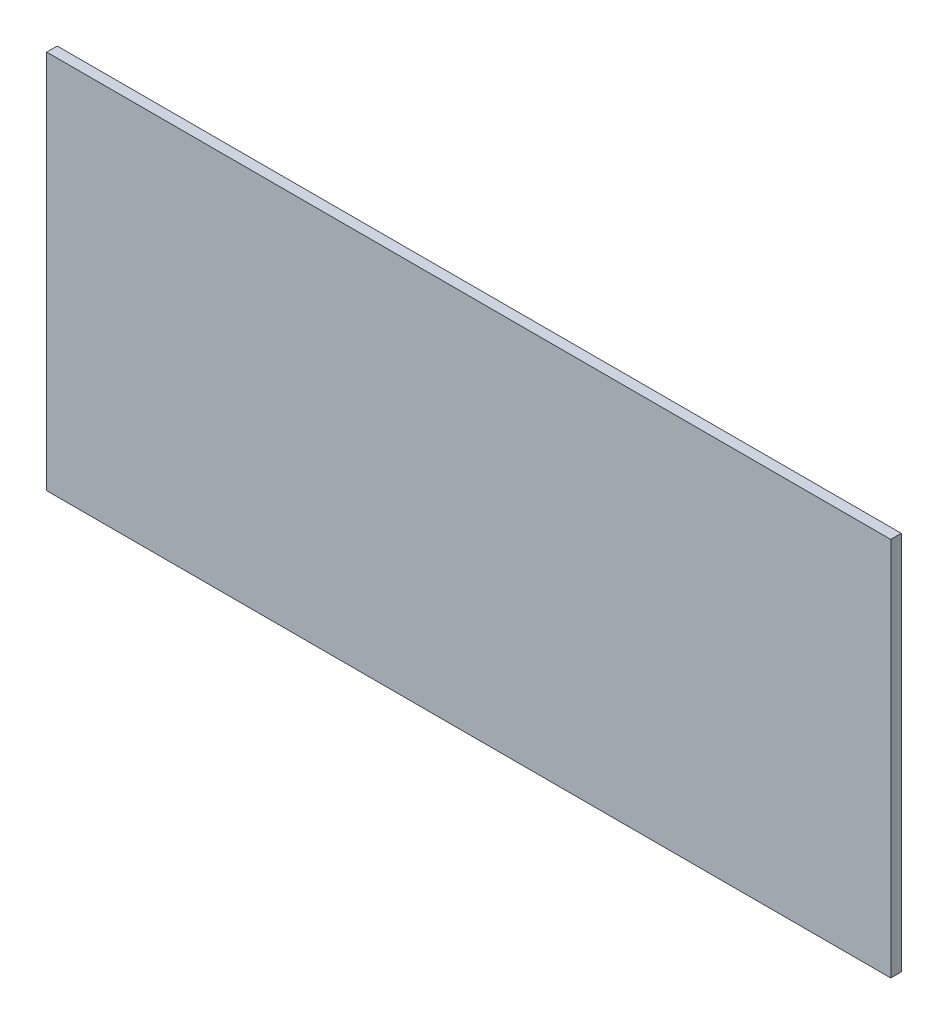
from build123d import *

# Parameters (mm, degrees)
SKETCH1_W           = 2032
SKETCH1_H           = 914.4
BOSS_EXTRUDE1_DEPTH = 25.4


with BuildPart() as part:
    # Sketch1 → Boss-Extrude1 (new body)
    with BuildSketch(Plane.XY):
        with Locations((1016, -457.2)):
            Rectangle(SKETCH1_W, SKETCH1_H)
    extrude(amount=BOSS_EXTRUDE1_DEPTH)


solid = part.part
